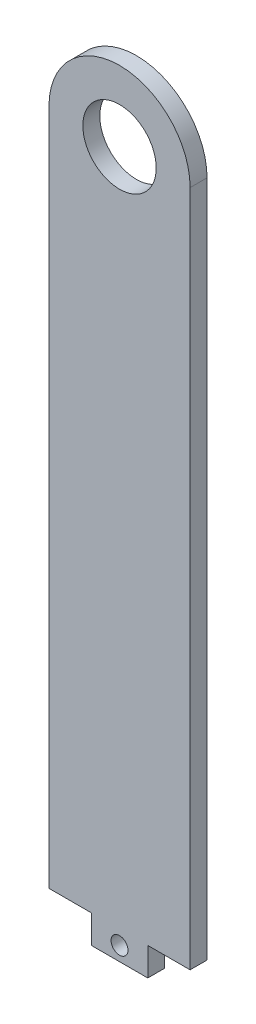
from build123d import *

# Parameters (mm, degrees)
SKETCH1_R           = 13
BOSS_EXTRUDE1_DEPTH = 6
SKETCH2_W           = 20
SKETCH2_H           = 10
SKETCH2_R           = 3
BOSS_EXTRUDE2_DEPTH = 6


with BuildPart() as part:
    # Sketch1 → Boss-Extrude1 (new body)
    with BuildSketch(Plane.XY):
        with BuildLine():
            Line((-25, -120), (25, -120))
            Line((25, -120), (25, 120))
            ThreePointArc((25, 120), (0, 145), (-25, 120))
            Line((-25, 120), (-25, -120))
        make_face()
        with Locations((0, 120)):
            Circle(SKETCH1_R, mode=Mode.SUBTRACT)
    extrude(amount=BOSS_EXTRUDE1_DEPTH)

    # Sketch2 → Boss-Extrude2 (add)
    with BuildSketch(Plane(origin=(0, 0, 0), x_dir=(-1, 0, 0), z_dir=(0, 0, -1))):
        with Locations((0, -125)):
            Rectangle(SKETCH2_W, SKETCH2_H)
        with Locations((0, -125)):
            Circle(SKETCH2_R, mode=Mode.SUBTRACT)
    extrude(amount=-BOSS_EXTRUDE2_DEPTH)


solid = part.part
